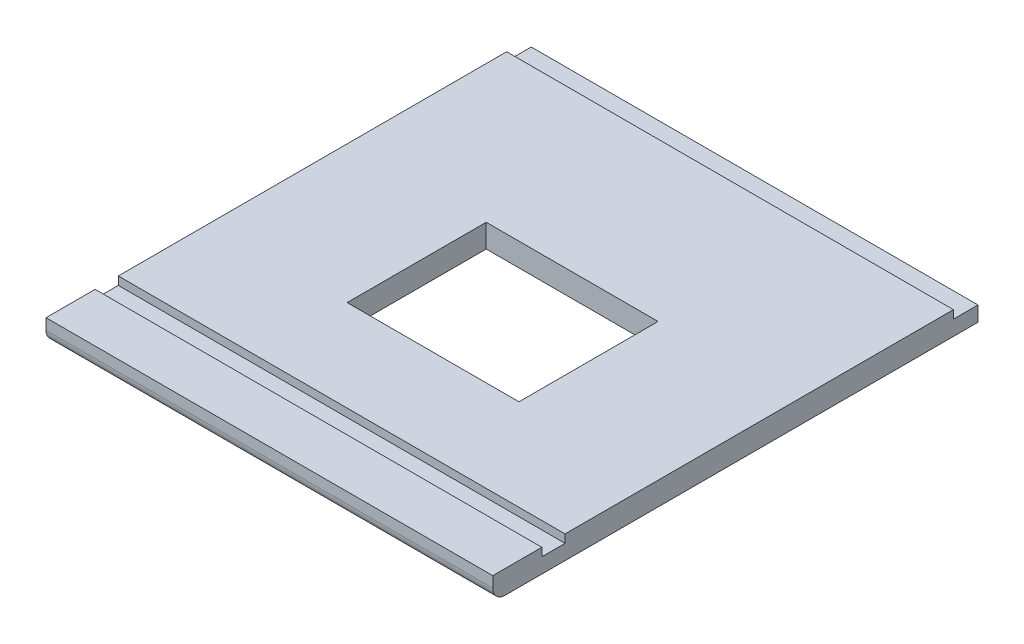
from build123d import *

# Parameters (mm, degrees)
SKETCH1_W           = 346.7
SKETCH1_H           = 376.55000001
BOSS_EXTRUDE1_DEPTH = 18
SKETCH2_W           = 346.7
SKETCH2_H           = 18
CUT_EXTRUDE1_DEPTH  = 6.35
SKETCH3_W           = 133.35
SKETCH3_H           = 107.95
CUT_EXTRUDE3_DEPTH  = 19
FILLET1_R           = 9.525
SKETCH6_W           = 346.7
SKETCH6_H           = 19.05
CUT_EXTRUDE4_DEPTH  = 6.35


with BuildPart() as part:
    # Sketch1 → Boss-Extrude1 (new body)
    with BuildSketch(Plane(origin=(0, 0, 0), x_dir=(1, 0, 0), z_dir=(0, 1, 0))):
        with Locations((173.35, -188.275000005)):
            Rectangle(SKETCH1_W, SKETCH1_H)
    extrude(amount=BOSS_EXTRUDE1_DEPTH)

    # Sketch2 → Cut-Extrude1 (cut)
    with BuildSketch(Plane(origin=(0, 18, 0), x_dir=(1, 0, 0), z_dir=(0, 1, 0))):
        with Locations((173.35, -329.45000001)):
            Rectangle(SKETCH2_W, SKETCH2_H)
    extrude(amount=-CUT_EXTRUDE1_DEPTH, mode=Mode.SUBTRACT)

    # Sketch3 → Cut-Extrude3 (cut, through all)
    with BuildSketch(Plane(origin=(0, 18, 0), x_dir=(1, 0, 0), z_dir=(0, 1, 0))):
        with Locations((173.35, -195.57500001)):
            Rectangle(SKETCH3_W, SKETCH3_H)
    extrude(amount=-CUT_EXTRUDE3_DEPTH, mode=Mode.SUBTRACT)

    # Fillet1
    fillet1_edges = [part.edges().sort_by_distance(p)[0] for p in [
        (173.35, 0, 376.55000001),
    ]]
    fillet(fillet1_edges, radius=FILLET1_R)

    # Sketch6 → Cut-Extrude4 (cut)
    with BuildSketch(Plane(origin=(0, 18, 0), x_dir=(1, 0, 0), z_dir=(0, 1, 0))):
        with Locations((173.35, -9.525)):
            Rectangle(SKETCH6_W, SKETCH6_H)
    extrude(amount=-CUT_EXTRUDE4_DEPTH, mode=Mode.SUBTRACT)


solid = part.part
